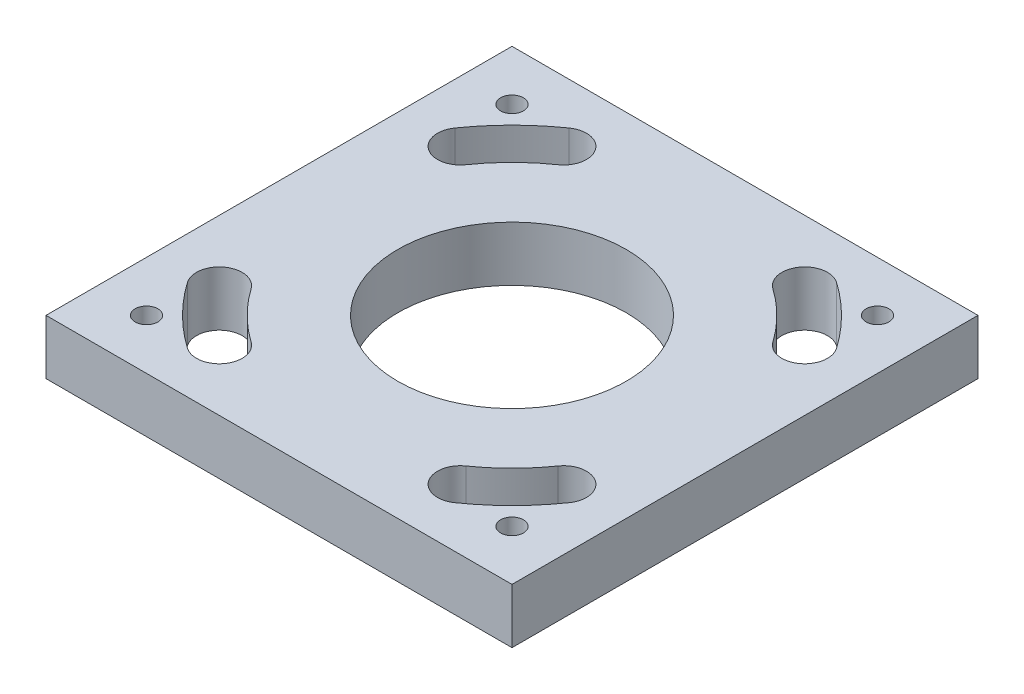
from build123d import *

# Parameters (mm, degrees)
ESQUISSE1_W           = 161.925
ESQUISSE1_H           = 161.925
ESQUISSE1_R           = 39.6875
BOSS_EXTRU_1_DEPTH    = 19.05
TROU_TARAUD_3_8_161_D = 7.9375


with BuildPart() as part:
    # Esquisse1 → Boss.-Extru.1 (new body)
    with BuildSketch(Plane(origin=(0, 0, 0), x_dir=(1, 0, 0), z_dir=(0, 1, 0))):
        Rectangle(ESQUISSE1_W, ESQUISSE1_H)
        Circle(ESQUISSE1_R, mode=Mode.SUBTRACT)
        with BuildLine():
            ThreePointArc((-46.438182228, 66.320597386), (-57.249132772, 57.249132772), (-66.320597386, 46.438182228))
            ThreePointArc((-66.320597386, 46.438182228), (-64.371340998, 35.383399913), (-53.316558683, 37.332656301))
            ThreePointArc((-53.316558683, 37.332656301), (-46.02381262, 46.02381262), (-37.332656301, 53.316558683))
            ThreePointArc((-37.332656301, 53.316558683), (-35.383399913, 64.371340998), (-46.438182228, 66.320597386))
        make_face(mode=Mode.SUBTRACT)
        with BuildLine():
            ThreePointArc((66.320597386, 46.438182228), (57.249132772, 57.249132772), (46.438182228, 66.320597386))
            ThreePointArc((46.438182228, 66.320597386), (35.383399913, 64.371340998), (37.332656301, 53.316558683))
            ThreePointArc((37.332656301, 53.316558683), (46.02381262, 46.02381262), (53.316558683, 37.332656301))
            ThreePointArc((53.316558683, 37.332656301), (64.371340998, 35.383399913), (66.320597386, 46.438182228))
        make_face(mode=Mode.SUBTRACT)
        with BuildLine():
            ThreePointArc((46.438182228, -66.320597386), (57.249132772, -57.249132772), (66.320597386, -46.438182228))
            ThreePointArc((66.320597386, -46.438182228), (64.371340998, -35.383399913), (53.316558683, -37.332656301))
            ThreePointArc((53.316558683, -37.332656301), (46.02381262, -46.02381262), (37.332656301, -53.316558683))
            ThreePointArc((37.332656301, -53.316558683), (35.383399913, -64.371340998), (46.438182228, -66.320597386))
        make_face(mode=Mode.SUBTRACT)
        with BuildLine():
            ThreePointArc((-66.320597386, -46.438182228), (-57.249132772, -57.249132772), (-46.438182228, -66.320597386))
            ThreePointArc((-46.438182228, -66.320597386), (-35.383399913, -64.371340998), (-37.332656301, -53.316558683))
            ThreePointArc((-37.332656301, -53.316558683), (-46.02381262, -46.02381262), (-53.316558683, -37.332656301))
            ThreePointArc((-53.316558683, -37.332656301), (-64.371340998, -35.383399913), (-66.320597386, -46.438182228))
        make_face(mode=Mode.SUBTRACT)
    extrude(amount=-BOSS_EXTRU_1_DEPTH)

    # Trou taraudé 3/8-161 (through all)
    with Locations(Plane(origin=(0, 0, 0), x_dir=(1, 0, 0), z_dir=(0, 1, 0))):
        with Locations((-63.5, 63.5), (63.5, 63.5), (-63.5, -63.5), (63.5, -63.5)):
            Hole(TROU_TARAUD_3_8_161_D / 2)


solid = part.part
